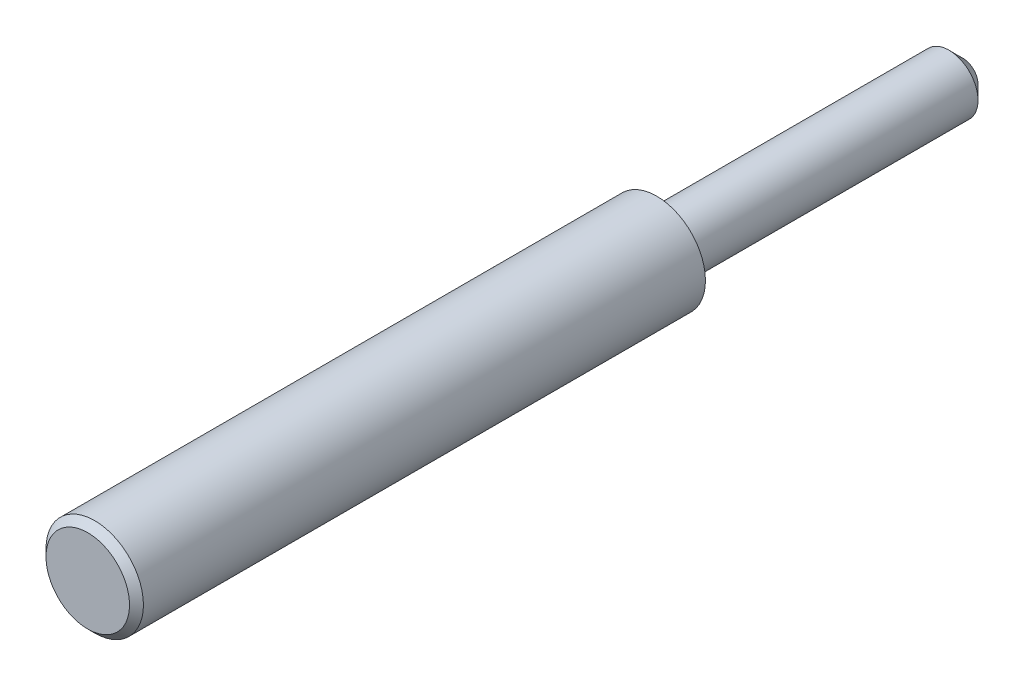
from build123d import *

# Parameters (mm, degrees)
CHAMFER1_SIZE = 1
CHAMFER2_SIZE = 0.5


with BuildPart() as part:
    # Sketch1 → Revolve1 (revolve)
    with BuildSketch(Plane(origin=(0, 0, 0), x_dir=(0, 0, -1), z_dir=(1, 0, 0)), mode=Mode.PRIVATE) as revolve1_sk:
        Polygon((22, 0), (22, 2.0828), (0, 2.0828), (0, 3.5), (-40.879, 3.5), (-40.879, 0), align=None)
    revolve(revolve1_sk.sketch.rotate(Axis((0, 0, 0), (0, 0, -1)), 90), axis=Axis((0, 0, 0), (0, 0, -1)))  # turned: the seam where the file's is

    # Chamfer1
    chamfer1_edges = [part.edges().sort_by_distance(p)[0] for p in [
        (-2.0828, 0, -22),
    ]]
    chamfer(chamfer1_edges, length=CHAMFER1_SIZE)

    # Chamfer2
    chamfer2_edges = [part.edges().sort_by_distance(p)[0] for p in [
        (-3.5, 0, 40.879),
    ]]
    chamfer(chamfer2_edges, length=CHAMFER2_SIZE)


solid = part.part
